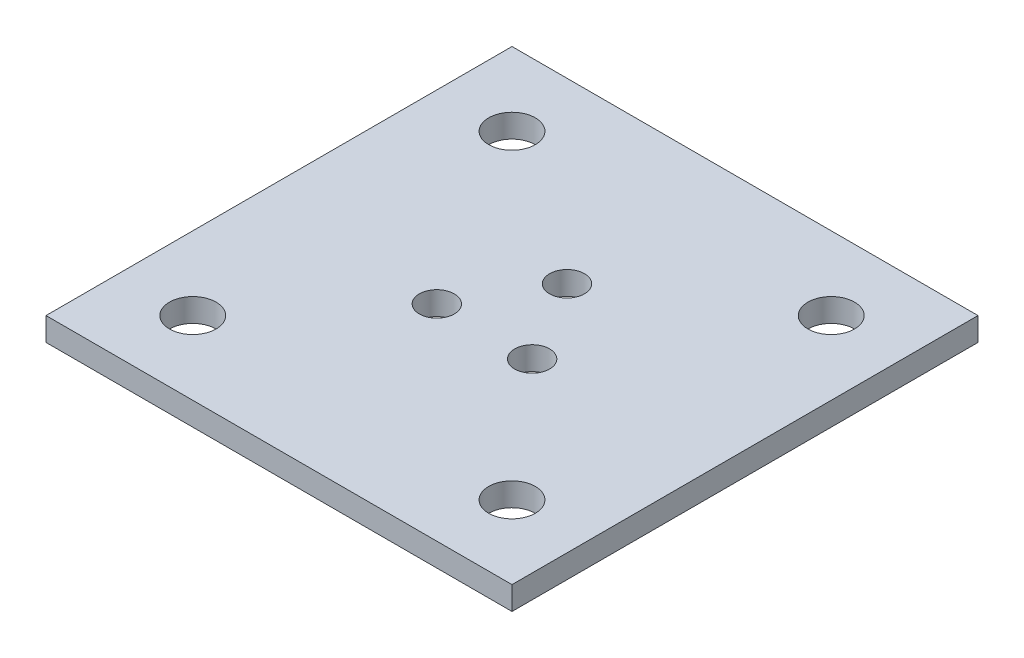
from build123d import *

# Parameters (mm, degrees)
SKETCH1_W           = 63.5
SKETCH1_H           = 63.5
BOSS_EXTRUDE1_DEPTH = 3.175
SKETCH2_R           = 2.38125
CUT_EXTRUDE1_DEPTH  = 4.175
SKETCH3_R           = 3.175
CUT_EXTRUDE2_DEPTH  = 4.175


with BuildPart() as part:
    # Sketch1 → Boss-Extrude1 (new body)
    with BuildSketch(Plane(origin=(0, 0, 0), x_dir=(1, 0, 0), z_dir=(0, 1, 0))):
        Rectangle(SKETCH1_W, SKETCH1_H)
    extrude(amount=BOSS_EXTRUDE1_DEPTH)

    # Sketch2 → Cut-Extrude1 (cut, through all)
    with BuildSketch(Plane(origin=(0, 3.175, 0), x_dir=(1, 0, 0), z_dir=(0, 1, 0))):
        with Locations((0, 7.5)):
            Circle(SKETCH2_R)
        with Locations((6.495190528, -3.75)):
            Circle(SKETCH2_R)
        with Locations((-6.495190528, -3.75)):
            Circle(SKETCH2_R)
    extrude(amount=-CUT_EXTRUDE1_DEPTH, mode=Mode.SUBTRACT)

    # Sketch3 → Cut-Extrude2 (cut, through all)
    with BuildSketch(Plane(origin=(0, 3.175, 0), x_dir=(1, 0, 0), z_dir=(0, 1, 0))):
        with Locations((-21.75, 21.75)):
            Circle(SKETCH3_R)
        with Locations((-21.75, -21.75)):
            Circle(SKETCH3_R)
        with Locations((21.75, -21.75)):
            Circle(SKETCH3_R)
        with Locations((21.75, 21.75)):
            Circle(SKETCH3_R)
    extrude(amount=-CUT_EXTRUDE2_DEPTH, mode=Mode.SUBTRACT)


solid = part.part
